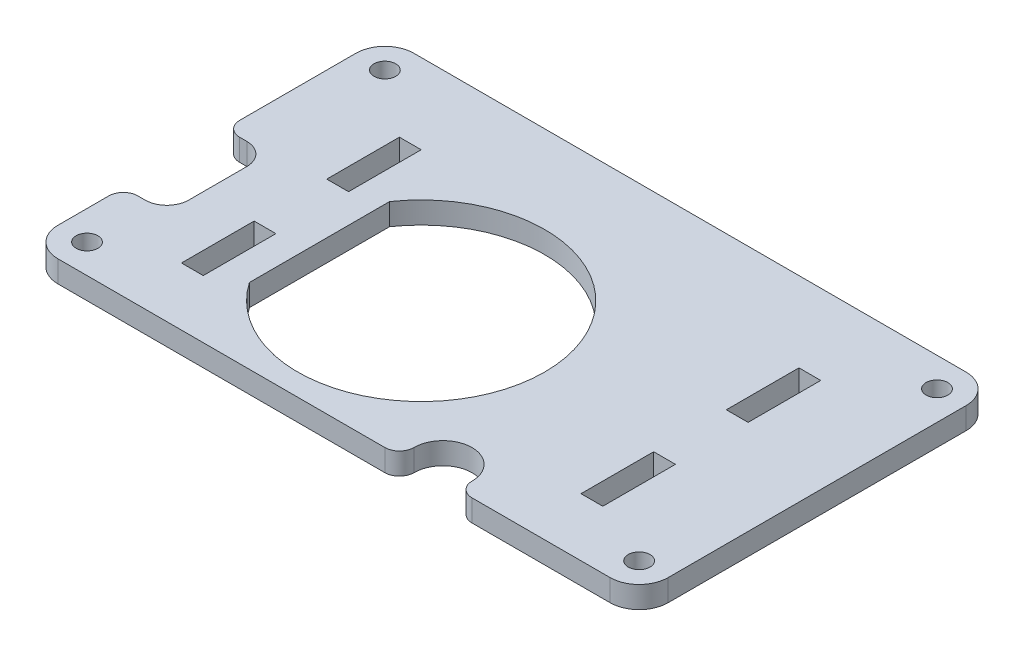
from build123d import *

# Parameters (mm, degrees)
SKETCH1_R           = 1.5
SKETCH1_W           = 3
SKETCH1_H           = 10
BOSS_EXTRUDE2_DEPTH = 3


with BuildPart() as part:
    # Sketch1 → Boss-Extrude2 (new body)
    with BuildSketch(Plane(origin=(0, 0, 0), x_dir=(1, 0, 0), z_dir=(0, 1, 0))):
        with BuildLine():
            Line((-42, 30.22741889), (-42, 14.22741889))
            ThreePointArc((-42, 14.22741889), (-41.414213562, 12.813205328), (-40, 12.22741889))
            Line((-40, 12.22741889), (-39, 12.22741889))
            ThreePointArc((-39, 12.22741889), (-36.878679656, 11.348739234), (-36, 9.22741889))
            Line((-36, 9.22741889), (-36, 1.22741889))
            ThreePointArc((-36, 1.22741889), (-36.878679656, -0.893901454), (-39, -1.77258111))
            Line((-39, -1.77258111), (-40, -1.77258111))
            ThreePointArc((-40, -1.77258111), (-41.414213562, -2.358367548), (-42, -3.77258111))
            Line((-42, -3.77258111), (-42, -10.77258111))
            ThreePointArc((-42, -10.77258111), (-40.828427125, -13.601008235), (-38, -14.77258111))
            Line((-38, -14.77258111), (7, -14.77258111))
            ThreePointArc((7, -14.77258111), (8.414213562, -14.186794672), (9, -12.77258111))
            ThreePointArc((9, -12.77258111), (13, -8.77258111), (17, -12.77258111))
            ThreePointArc((17, -12.77258111), (17.585786438, -14.186794672), (19, -14.77258111))
            Line((19, -14.77258111), (38, -14.77258111))
            ThreePointArc((38, -14.77258111), (40.828427125, -13.601008235), (42, -10.77258111))
            Line((42, -10.77258111), (42, 30.22741889))
            ThreePointArc((42, 30.22741889), (40.828427125, 33.055846015), (38, 34.22741889))
            Line((38, 34.22741889), (-38, 34.22741889))
            ThreePointArc((-38, 34.22741889), (-40.828427125, 33.055846015), (-42, 30.22741889))
        make_face()
        with Locations((38, 30.22741889)):
            Circle(SKETCH1_R, mode=Mode.SUBTRACT)
        with Locations((38, -10.77258111)):
            Circle(SKETCH1_R, mode=Mode.SUBTRACT)
        with Locations((-38, -10.77258111)):
            Circle(SKETCH1_R, mode=Mode.SUBTRACT)
        with Locations((-38, 30.22741889)):
            Circle(SKETCH1_R, mode=Mode.SUBTRACT)
        with Locations((27.5, -1.77258111)):
            Rectangle(SKETCH1_W, SKETCH1_H, mode=Mode.SUBTRACT)
        with Locations((27.5, 18.22741889)):
            Rectangle(SKETCH1_W, SKETCH1_H, mode=Mode.SUBTRACT)
        with Locations((-27.5, 18.22741889)):
            Rectangle(SKETCH1_W, SKETCH1_H, mode=Mode.SUBTRACT)
        with Locations((-27.5, -1.77258111)):
            Rectangle(SKETCH1_W, SKETCH1_H, mode=Mode.SUBTRACT)
        with BuildLine():
            Line((-22, -4.416231871), (-22, 14.871069651))
            ThreePointArc((-22, 14.871069651), (9, 5.22741889), (-22, -4.416231871))
        make_face(mode=Mode.SUBTRACT)
    extrude(amount=BOSS_EXTRUDE2_DEPTH)


solid = part.part
